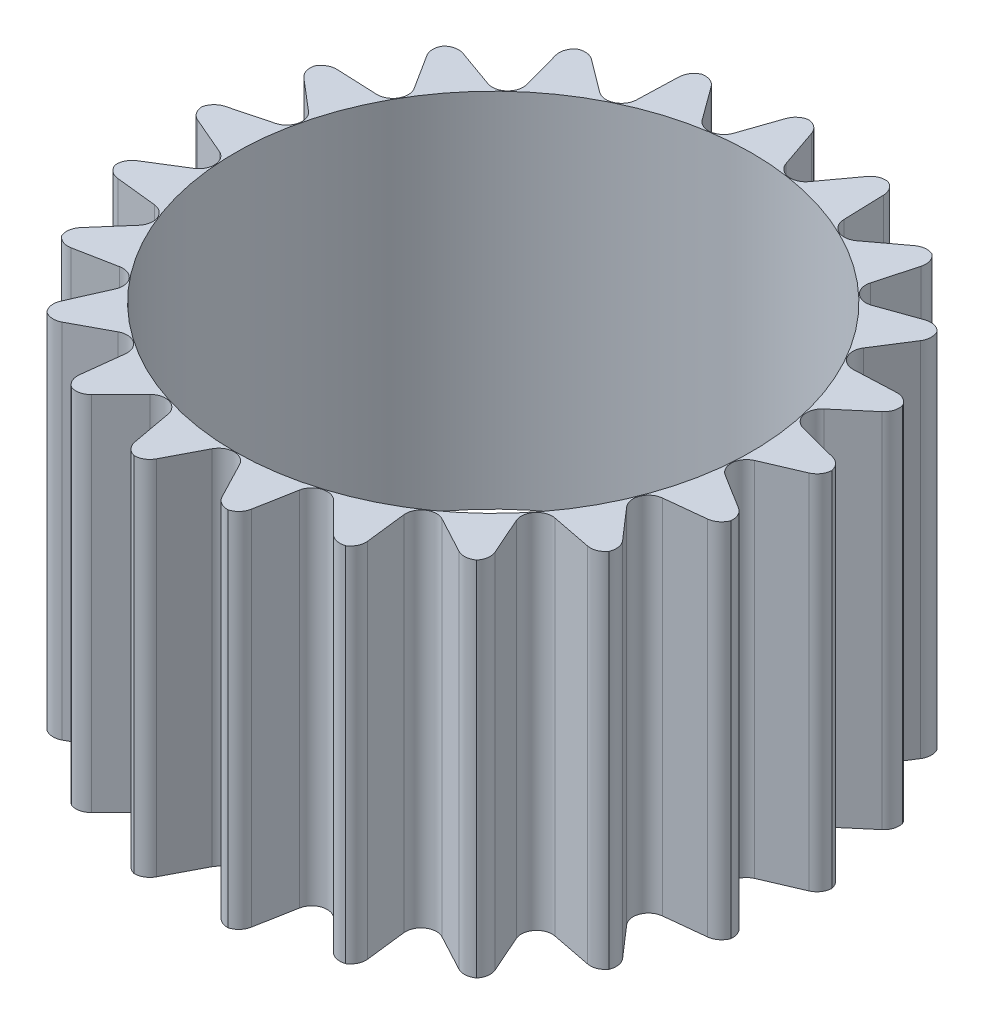
from build123d import *

# Parameters (mm, degrees)
SKETCH1_R           = 6.11
SKETCH1_R_2         = 5
BOSS_EXTRUDE1_DEPTH = 7
CUT_EXTRUDE2_DEPTH  = 7
CIRPATTERN1_COUNT   = 21


with BuildPart() as part:
    # Sketch1 → Boss-Extrude1 (new body)
    with BuildSketch(Plane(origin=(0, 0, 0), x_dir=(1, 0, 0), z_dir=(0, 1, 0))):
        Circle(SKETCH1_R)
        Circle(SKETCH1_R_2, mode=Mode.SUBTRACT)
    extrude(amount=BOSS_EXTRUDE1_DEPTH)

    # Sketch2 → Cut-Extrude2 (cut)
    with BuildSketch(Plane(origin=(0, 0, 0), x_dir=(1, 0, 0), z_dir=(0, 1, 0))):
        with BuildLine():
            Line((0.634953715, -5.878485528), (0.265979235, -5.171237446))
            ThreePointArc((0.265979235, -5.171237446), (0, -5.01), (-0.265979235, -5.171237446))
            Line((-0.265979235, -5.171237446), (-0.634953715, -5.878485528))
            ThreePointArc((-0.634953715, -5.878485528), (-0.765837658, -6.007583501), (-0.947452724, -6.036094212))
            ThreePointArc((-0.947452724, -6.036094212), (0, -7.060330853), (0.947452724, -6.036094212))
            ThreePointArc((0.947452724, -6.036094212), (0.765837658, -6.007583501), (0.634953715, -5.878485528))
        make_face()
    cut_extrude2 = extrude(amount=CUT_EXTRUDE2_DEPTH, mode=Mode.SUBTRACT)

    # CirPattern1: Cut-Extrude2 ×21 about axis
    cirpattern1_axis = Axis((0, 0, 0), (0, 1, 0))
    for i in range(1, CIRPATTERN1_COUNT):
        add(cut_extrude2.rotate(cirpattern1_axis, i * 360 / CIRPATTERN1_COUNT), mode=Mode.SUBTRACT)


solid = part.part
